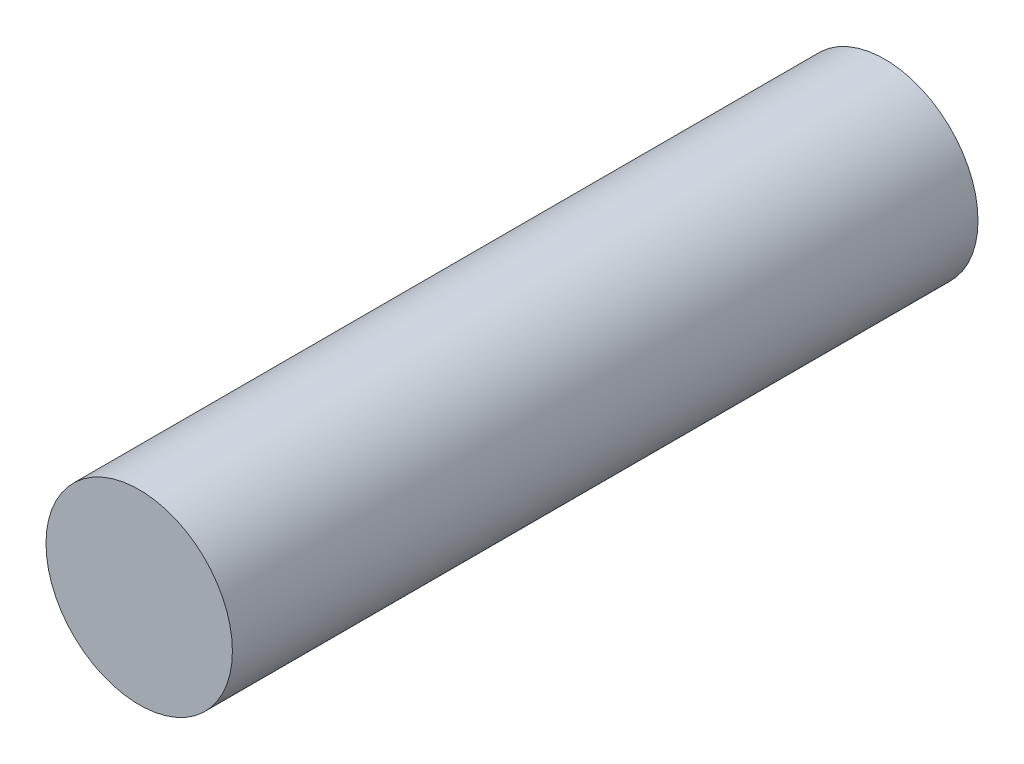
from build123d import *

# Parameters (mm, degrees)
SKETCH1_R           = 3.75
BOSS_EXTRUDE1_DEPTH = 30


with BuildPart() as part:
    # Sketch1 → Boss-Extrude1 (new body)
    with BuildSketch(Plane.XY):
        Circle(SKETCH1_R)
    extrude(amount=BOSS_EXTRUDE1_DEPTH)


solid = part.part
